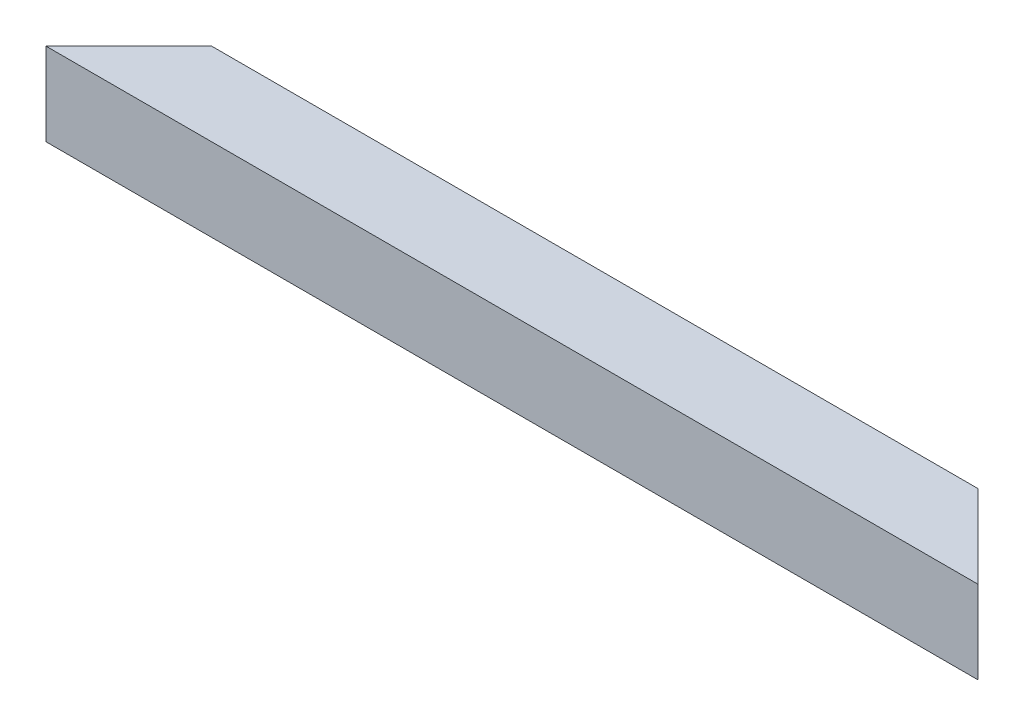
from build123d import *

# Parameters (mm, degrees)
SKETCH1_W           = 285.8
SKETCH1_H           = 25.4
BOSS_EXTRUDE1_DEPTH = 25.4
SKETCH2_W           = 23
SKETCH2_H           = 23
CUT_EXTRUDE1_DEPTH  = 450
CUT_EXTRUDE2_DEPTH  = 25.4


with BuildPart() as part:
    # Sketch1 → Boss-Extrude1 (new body)
    with BuildSketch(Plane(origin=(0, 0, 0), x_dir=(1, 0, 0), z_dir=(0, 1, 0))):
        with Locations((142.9, 12.7)):
            Rectangle(SKETCH1_W, SKETCH1_H)
    extrude(amount=BOSS_EXTRUDE1_DEPTH)

    # Sketch2 → Cut-Extrude1 (cut)
    with BuildSketch(Plane(origin=(285.8, 0, 0), x_dir=(0, 0, -1), z_dir=(1, 0, 0))):
        with Locations((12.7, 12.7)):
            Rectangle(SKETCH2_W, SKETCH2_H)
    extrude(amount=-CUT_EXTRUDE1_DEPTH, mode=Mode.SUBTRACT)

    # Sketch3 → Cut-Extrude2 (cut)
    with BuildSketch(Plane(origin=(0, 25.4, 0), x_dir=(1, 0, 0), z_dir=(0, 1, 0))):
        Polygon((0, 0), (25.4, 25.4), (0, 25.4), align=None)
        Polygon((285.8, 0), (260.4, 25.4), (285.8, 25.4), align=None)
    extrude(amount=-CUT_EXTRUDE2_DEPTH, mode=Mode.SUBTRACT)


solid = part.part
